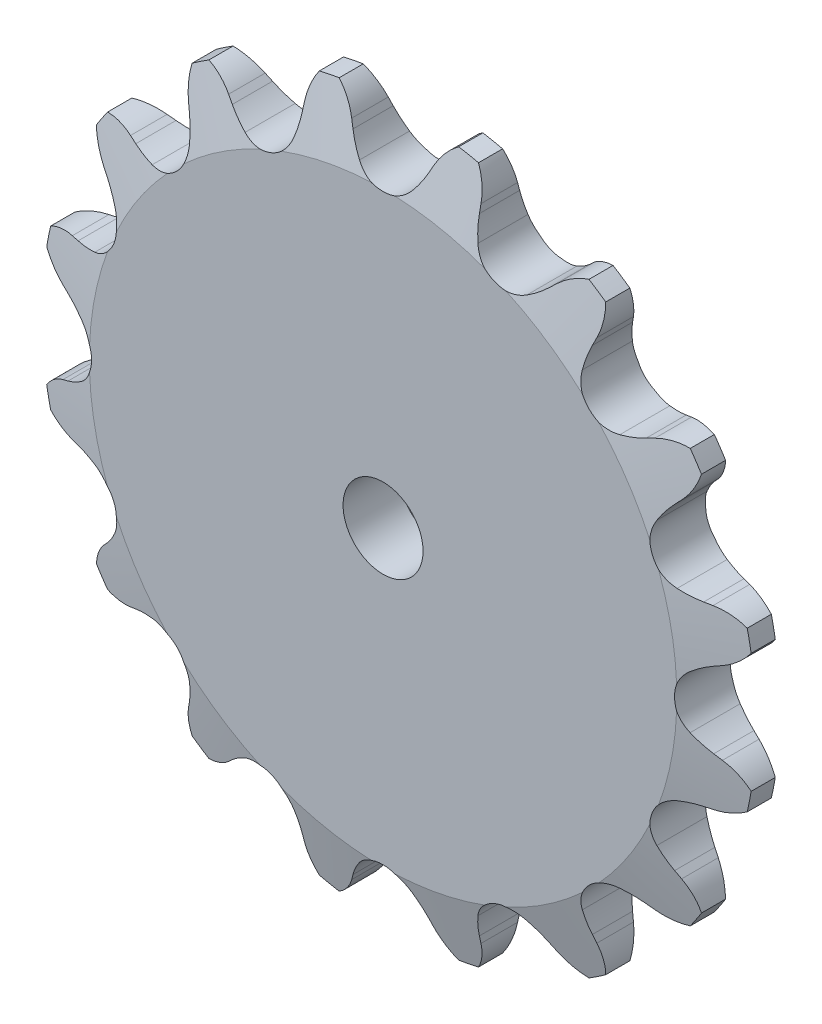
from build123d import *

# Parameters (mm, degrees)
TOOTH_CUT_NUMBER_OF_TEETH_16_DEPTH = 26.306064487
TOOTH_PATTERN_16_16_COUNT          = 16
CUT_EXTRUDE1_DEPTH                 = 25.950439678
CUT_EXTRUDE1_DEPTH_BACK            = 25.950439678
SKETCH4_R                          = 2


with BuildPart() as part:
    # Sprocket-BaseSketch → 25 _04C_ ANSI _ISO_ Chain Number_ 1.281i (revolve)
    with BuildSketch(Plane(origin=(0, 0, 0), x_dir=(0, 0, -1), z_dir=(1, 0, 0))):
        Polygon((1.397, 0), (1.397, 14.691802887), (0.60325, 17.866802887), (-0.60325, 17.866802887), (-1.397, 14.691802887), (-1.397, 0), align=None)
    revolve(axis=Axis((0, 0, -5.588), (0, 0, 1)))

    # Tooth-Sketch → Tooth-Cut_ Number of teeth_ 16 (cut, symmetric)
    with BuildSketch(Plane.XY):
        with BuildLine():
            Line((1.895951627, 16.145861918), (2.051408678, 16.490963774))
            ThreePointArc((2.051408678, 16.490963774), (3.056004647, 17.659429879), (4.533974194, 18.095471295))
            ThreePointArc((4.533974194, 18.095471295), (0, 18.654838605), (-4.533974194, 18.095471295))
            ThreePointArc((-4.533974194, 18.095471295), (-3.056004647, 17.659429879), (-2.051408678, 16.490963774))
            Line((-2.051408678, 16.490963774), (-1.895951627, 16.145861918))
            ThreePointArc((-1.895951627, 16.145861918), (-1.639424454, 15.660854777), (-1.323740827, 15.212098758))
            ThreePointArc((-1.323740827, 15.212098758), (0, 14.577158093), (1.323740827, 15.212098758))
            ThreePointArc((1.323740827, 15.212098758), (1.639424454, 15.660854777), (1.895951627, 16.145861918))
        make_face()
    tooth_cut_number_of_teeth_16 = extrude(amount=TOOTH_CUT_NUMBER_OF_TEETH_16_DEPTH, both=True, mode=Mode.SUBTRACT)

    # Tooth Pattern_ 16 _ 16: Tooth-Cut_ Number of teeth_ 16 ×16 about axis
    tooth_pattern_16_16_axis = Axis((0, 0, -88.99), (0, 0, 1))
    for i in range(1, TOOTH_PATTERN_16_16_COUNT):
        add(tooth_cut_number_of_teeth_16.rotate(tooth_pattern_16_16_axis, i * 360 / TOOTH_PATTERN_16_16_COUNT), mode=Mode.SUBTRACT)

    # Sketch4 → Cut-Extrude1 (cut, two sides: drawn at the far end of the back side and taken through both)
    with BuildSketch(Plane.XY.offset(-CUT_EXTRUDE1_DEPTH_BACK)):
        Circle(SKETCH4_R)
    extrude(amount=CUT_EXTRUDE1_DEPTH + CUT_EXTRUDE1_DEPTH_BACK, mode=Mode.SUBTRACT)


solid = part.part
